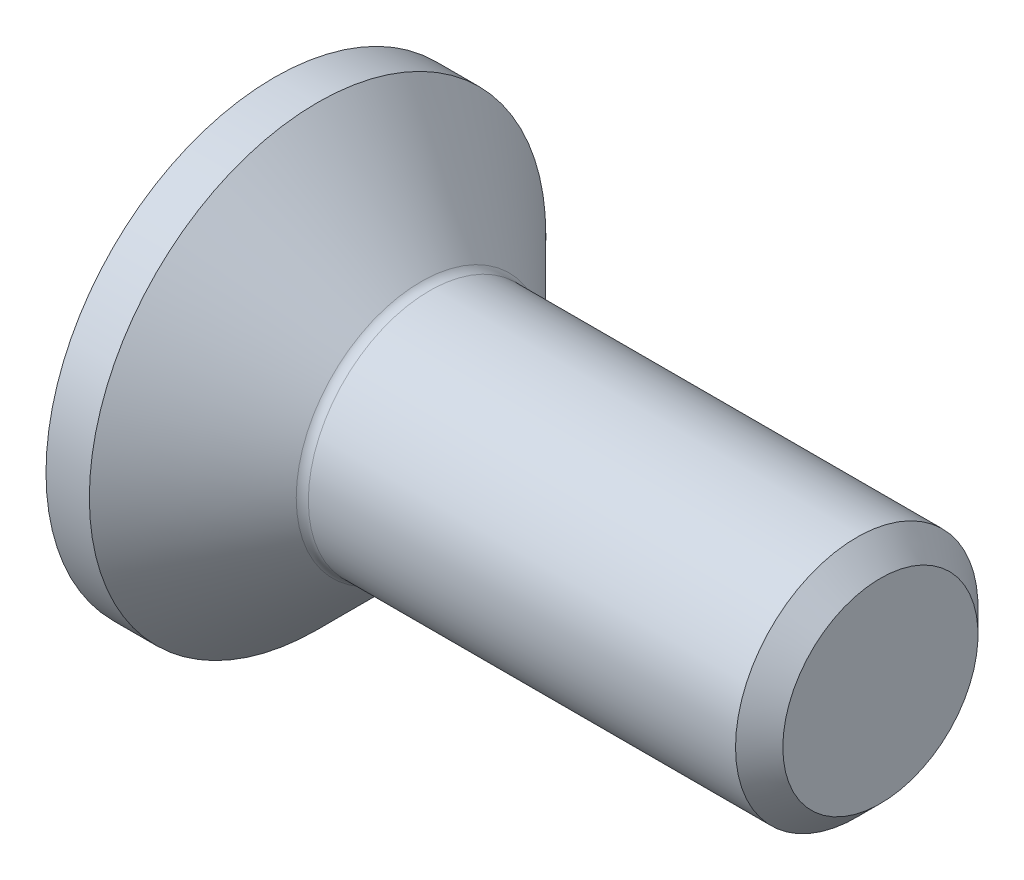
from build123d import *

# Parameters (mm, degrees)
FILLET1_R   = 0.2
HEX_2_DEPTH = 1.5


with BuildPart() as part:
    # BodySke → BaseBody (revolve)
    with BuildSketch(Plane.XY, mode=Mode.PRIVATE) as basebody_sk:
        Polygon((0, 0), (0, 3.765), (0.715, 3.765), (2.48, 2), (9.61, 2), (10, 1.61), (10, 0), align=None)
    revolve(basebody_sk.sketch.rotate(Axis((0, 0, 0), (1, 0, 0)), 90), axis=Axis((0, 0, 0), (1, 0, 0)))  # turned: the seam where the file's is

    # Fillet1
    fillet1_edges = [part.edges().sort_by_distance(p)[0] for p in [
        (2.48, 0, -2),
    ]]
    fillet(fillet1_edges, radius=FILLET1_R)

    # Sketch2 → PreBroach (revolve, cut)
    with BuildSketch(Plane.XY, mode=Mode.PRIVATE) as prebroach_sk:
        Polygon((0, 1.25), (1.5, 1.25), (2.221687836, 0), (0, 0), align=None)
    revolve(prebroach_sk.sketch.rotate(Axis((0, 0, 0), (1, 0, 0)), 90), axis=Axis((0, 0, 0), (1, 0, 0)), mode=Mode.SUBTRACT)  # turned: the seam where the file's is

    # Sketch3 → Hex 2 (cut)
    with BuildSketch(Plane.ZY):
        Polygon((-1.25, -0.721687836), (-1.25, 0.721687836), (0, 1.443375673), (1.25, 0.721687836), (1.25, -0.721687836), (0, -1.443375673), align=None)
    extrude(amount=-HEX_2_DEPTH, mode=Mode.SUBTRACT)


solid = part.part
